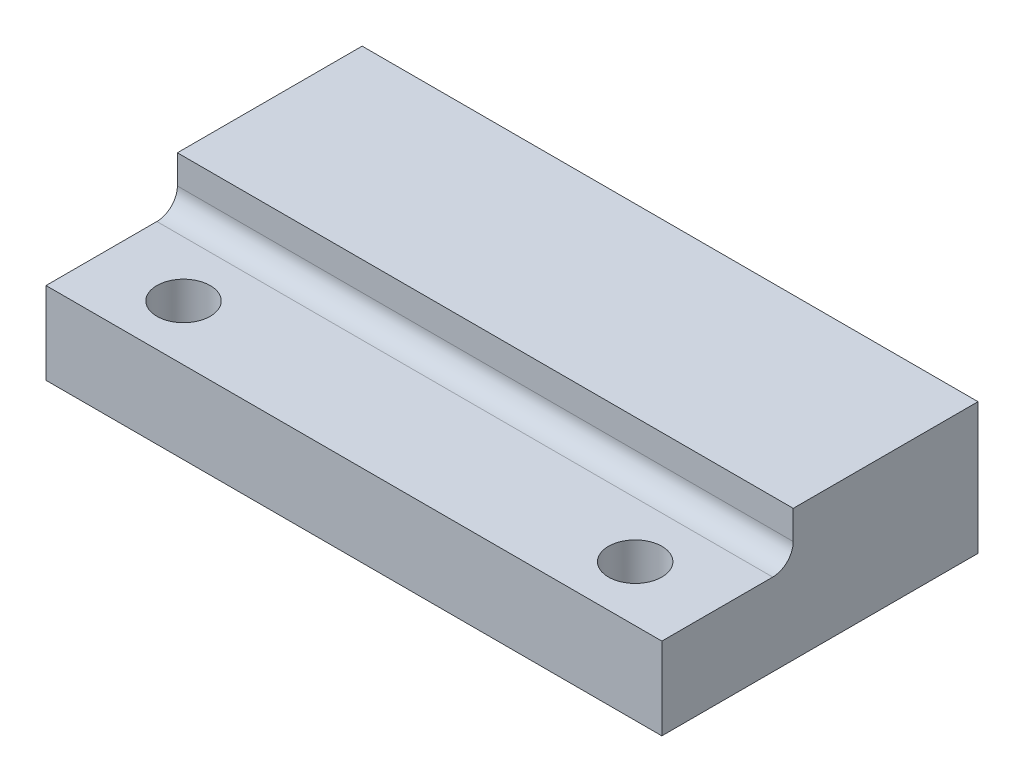
from build123d import *

# Parameters (mm, degrees)
SKETCH1_W                 = 30
SKETCH1_H                 = 15.4
BOSS_EXTRUDE1_DEPTH       = 6.4
SKETCH4_R                 = 1.3
CUT_EXTRUDE3_DEPTH        = 7.4
SKETCH8_W                 = 11.4
SKETCH8_H                 = 2.4
CUT_EXTRUDE4_DEPTH        = 31
SKETCH9_R                 = 0.5
CUT_EXTRUDE5_DEPTH        = 7
M2X0_4_TAPPED_HOLE1_D     = 1.6
M2X0_4_TAPPED_HOLE1_DEPTH = 7
M2X0_4_TAPPED_HOLE1_TIP   = 0.480688495
SKETCH14_W                = 30
SKETCH14_H                = 5
BOSS_EXTRUDE2_DEPTH       = 2.4
SKETCH13_R                = 1
CUT_EXTRUDE6_DEPTH        = 7
FILLET1_R                 = 1


with BuildPart() as part:
    # Sketch1 → Boss-Extrude1 (new body)
    with BuildSketch(Plane(origin=(0, 0, 0), x_dir=(1, 0, 0), z_dir=(0, 1, 0))):
        with Locations((-15, 7.7)):
            Rectangle(SKETCH1_W, SKETCH1_H)
    extrude(amount=BOSS_EXTRUDE1_DEPTH)

    # Sketch4 → Cut-Extrude3 (cut, through all)
    with BuildSketch(Plane(origin=(0, 0, 0), x_dir=(1, 0, 0), z_dir=(0, 1, 0))):
        with Locations((-26, 2.7)):
            Circle(SKETCH4_R)
        with Locations((-4, 2.7)):
            Circle(SKETCH4_R)
    extrude(amount=CUT_EXTRUDE3_DEPTH, mode=Mode.SUBTRACT)

    # Sketch8 → Cut-Extrude4 (cut, through all)
    with BuildSketch(Plane(origin=(0, 0, 0), x_dir=(0, 0, -1), z_dir=(1, 0, 0))):
        with Locations((5.7, 5.2)):
            Rectangle(SKETCH8_W, SKETCH8_H)
    extrude(amount=-CUT_EXTRUDE4_DEPTH, mode=Mode.SUBTRACT)

    # Sketch9 → Cut-Extrude5 (cut)
    with BuildSketch(Plane(origin=(0, 0, -15.4), x_dir=(-1, 0, 0), z_dir=(0, 0, -1))):
        with Locations((4, 3.7)):
            Circle(SKETCH9_R)
        with Locations((26, 3.7)):
            Circle(SKETCH9_R)
    extrude(amount=-CUT_EXTRUDE5_DEPTH, mode=Mode.SUBTRACT)

    # M2x0.4 Tapped Hole1
    with Locations(Plane(origin=(0, 0, -15.4), x_dir=(-1, 0, 0), z_dir=(0, 0, -1))):
        with Locations((4, 3.7), (26, 3.7)):
            Hole(M2X0_4_TAPPED_HOLE1_D / 2, depth=M2X0_4_TAPPED_HOLE1_DEPTH)
            with Locations((0, 0, -(M2X0_4_TAPPED_HOLE1_DEPTH + M2X0_4_TAPPED_HOLE1_TIP / 2))):  # 118° drill point
                Cone(0, M2X0_4_TAPPED_HOLE1_D / 2, M2X0_4_TAPPED_HOLE1_TIP, mode=Mode.SUBTRACT)

    # Sketch14 → Boss-Extrude2 (add)
    with BuildSketch(Plane(origin=(0, 6.4, 0), x_dir=(1, 0, 0), z_dir=(0, 1, 0))):
        with Locations((-15, 8.9)):
            Rectangle(SKETCH14_W, SKETCH14_H)
    extrude(amount=-BOSS_EXTRUDE2_DEPTH)

    # Sketch13 → Cut-Extrude6 (cut)
    with BuildSketch(Plane(origin=(0, 0, -15.4), x_dir=(-1, 0, 0), z_dir=(0, 0, -1))):
        with Locations((4, 3.7)):
            Circle(SKETCH13_R)
        with Locations((26, 3.7)):
            Circle(SKETCH13_R)
    extrude(amount=-CUT_EXTRUDE6_DEPTH, mode=Mode.SUBTRACT)

    # Fillet1
    fillet1_edges = [part.edges().sort_by_distance(p)[0] for p in [
        (-15, 4, -6.4),
    ]]
    fillet(fillet1_edges, radius=FILLET1_R)


solid = part.part
